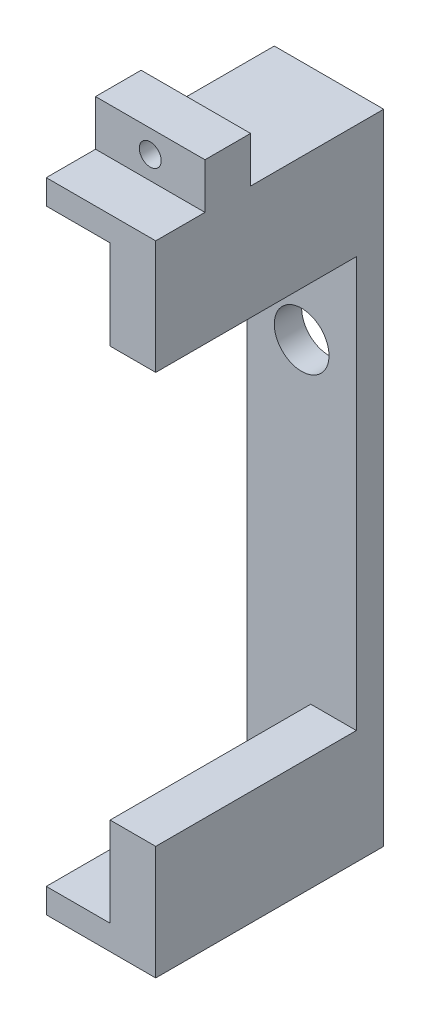
from build123d import *

# Parameters (mm, degrees)
CROQUIS1_W                 = 6
CROQUIS1_H                 = 35
SALIENTE_EXTRUIR1_DEPTH    = 12.5
CROQUIS2_W                 = 6
CROQUIS2_H                 = 22.5
CORTAR_EXTRUIR1_DEPTH      = 11
CROQUIS3_R                 = 1.5
CORTAR_EXTRUIR2_DEPTH      = 1
CORTAR_EXTRUIR2_DEPTH_BACK = 13.5
CROQUIS4_W                 = 3.5
CROQUIS4_H                 = 4.9
CORTAR_EXTRUIR3_DEPTH      = 1
CORTAR_EXTRUIR3_DEPTH_BACK = 11
CROQUIS5_W                 = 6
CROQUIS5_H                 = 2.5
SALIENTE_EXTRUIR2_DEPTH    = 2.5
CROQUIS6_R                 = 0.6
CORTAR_EXTRUIR4_DEPTH      = 3.7
CORTAR_EXTRUIR4_DEPTH_BACK = 10.8


with BuildPart() as part:
    # Croquis1 → Saliente-Extruir1 (new body)
    with BuildSketch(Plane.XY):
        Rectangle(CROQUIS1_W, CROQUIS1_H)
    extrude(amount=SALIENTE_EXTRUIR1_DEPTH)

    # Croquis2 → Cortar-Extruir1 (cut)
    with BuildSketch(Plane.XY.offset(12.5)):
        Rectangle(CROQUIS2_W, CROQUIS2_H)
    extrude(amount=-CORTAR_EXTRUIR1_DEPTH, mode=Mode.SUBTRACT)

    # Croquis3 → Cortar-Extruir2 (cut, two sides)
    with BuildSketch(Plane(origin=(0, 0, 0), x_dir=(-1, 0, 0), z_dir=(0, 0, -1))) as cortar_extruir2_sk:
        with Locations((0, 5.8)):
            Circle(CROQUIS3_R)
    extrude(amount=CORTAR_EXTRUIR2_DEPTH, mode=Mode.SUBTRACT)
    extrude(cortar_extruir2_sk.sketch, amount=-CORTAR_EXTRUIR2_DEPTH_BACK, mode=Mode.SUBTRACT)

    # Croquis4 → Cortar-Extruir3 (cut, two sides)
    with BuildSketch(Plane.XY.offset(12.5)) as cortar_extruir3_sk:
        with Locations((-1.25, 13.7)):
            Rectangle(CROQUIS4_W, CROQUIS4_H)
        with Locations((-1.25, -13.7)):
            Rectangle(CROQUIS4_W, CROQUIS4_H)
    extrude(amount=CORTAR_EXTRUIR3_DEPTH, mode=Mode.SUBTRACT)
    extrude(cortar_extruir3_sk.sketch, amount=-CORTAR_EXTRUIR3_DEPTH_BACK, mode=Mode.SUBTRACT)

    # Croquis5 → Saliente-Extruir2 (add)
    with BuildSketch(Plane.XZ.offset(-17.5)):
        with Locations((0, 8.55)):
            Rectangle(CROQUIS5_W, CROQUIS5_H)
    extrude(amount=-SALIENTE_EXTRUIR2_DEPTH)

    # Croquis6 → Cortar-Extruir4 (cut, two sides)
    with BuildSketch(Plane.XY.offset(9.8)) as cortar_extruir4_sk:
        with Locations((0, 18.75)):
            Circle(CROQUIS6_R)
    extrude(amount=CORTAR_EXTRUIR4_DEPTH, mode=Mode.SUBTRACT)
    extrude(cortar_extruir4_sk.sketch, amount=-CORTAR_EXTRUIR4_DEPTH_BACK, mode=Mode.SUBTRACT)


solid = part.part
